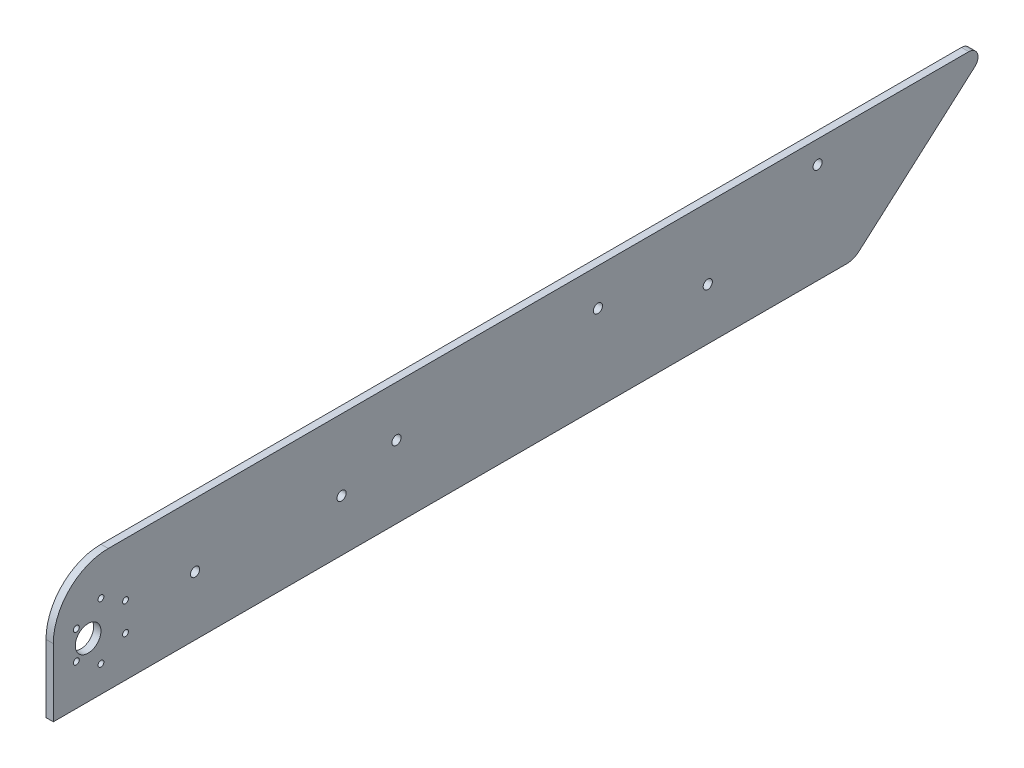
from build123d import *

# Parameters (mm, degrees)
SKETCH_1_R      = 2.5
SKETCH_1_R_2    = 7
SKETCH_1_R_3    = 1.6
EXTRUDE_1_DEPTH = 4
FILLET_1_R      = 30


with BuildPart() as part:
    # 草图1 → 凸台-拉伸1 (new body)
    with BuildSketch(Plane.ZY):
        with BuildLine():
            Line((-206.943801285, -7), (226.406668198, -7))
            Line((226.406668198, -7), (226.406668198, 60))
            Line((226.406668198, 60), (-273.593331802, 60))
            ThreePointArc((-273.593331802, 60), (-278.27128826, 56.76542442), (-276.896763228, 51.246689353))
            Line((-276.896763228, 51.246689353), (-213.550664137, -4.506621294))
            ThreePointArc((-213.550664137, -4.506621294), (-210.474650125, -6.355912915), (-206.943801285, -7))
        make_face()
        with Locations((-191.007742204, 47.848052121)):
            Circle(SKETCH_1_R, mode=Mode.SUBTRACT)
        with Locations((68.992257796, 21.23337925)):
            Circle(SKETCH_1_R, mode=Mode.SUBTRACT)
        with Locations((38.992257796, 32.549891061)):
            Circle(SKETCH_1_R, mode=Mode.SUBTRACT)
        with Locations((-131.007742204, 21.23337925)):
            Circle(SKETCH_1_R, mode=Mode.SUBTRACT)
        with Locations((207.406668198, 23.006889262)):
            Circle(SKETCH_1_R_2, mode=Mode.SUBTRACT)
        with Locations((148.992257796, 25.23337925)):
            Circle(SKETCH_1_R, mode=Mode.SUBTRACT)
        with Locations((-71.007742204, 39.866402872)):
            Circle(SKETCH_1_R, mode=Mode.SUBTRACT)
        with Locations((213.830061956, 30.756889262)):
            Circle(SKETCH_1_R_3, mode=Mode.SUBTRACT)
        with Locations((200.406668198, 38.506889262)):
            Circle(SKETCH_1_R_3, mode=Mode.SUBTRACT)
        with Locations((186.983274439, 30.756889262)):
            Circle(SKETCH_1_R_3, mode=Mode.SUBTRACT)
        with Locations((186.983274439, 15.256889262)):
            Circle(SKETCH_1_R_3, mode=Mode.SUBTRACT)
        with Locations((200.406668198, 7.506889262)):
            Circle(SKETCH_1_R_3, mode=Mode.SUBTRACT)
        with Locations((213.830061956, 15.256889262)):
            Circle(SKETCH_1_R_3, mode=Mode.SUBTRACT)
    extrude(amount=EXTRUDE_1_DEPTH)

    # 圆角1
    fillet_1_edges = [part.edges().sort_by_distance(p)[0] for p in [
        (-2, 60, 226.406668198),
    ]]
    fillet(fillet_1_edges, radius=FILLET_1_R)


solid = part.part
